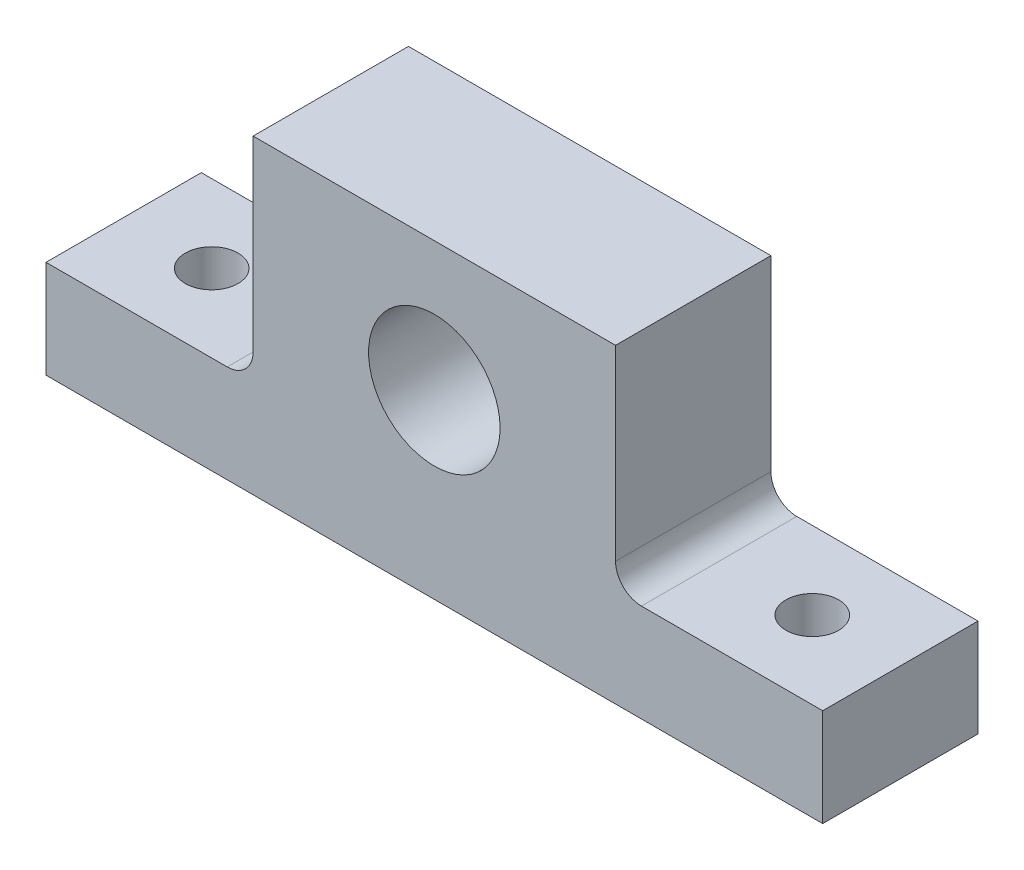
from build123d import *

# Parameters (mm, degrees)
BOSS_EXTRUDE1_DEPTH               = 30
F_1_1_0000_DOWEL_HOLE1_D          = 25.4
TAP_DRILL_FOR_M12X1_75_TAP1_D     = 10.2
TAP_DRILL_FOR_M12X1_75_TAP1_DEPTH = 30
TAP_DRILL_FOR_M12X1_75_TAP1_TIP   = 3.064389157


with BuildPart() as part:
    # Sketch1 → Boss-Extrude1 (new body)
    with BuildSketch(Plane.XY):
        with BuildLine():
            Line((-75, -23.452240915), (75, -23.452240915))
            Line((75, -23.452240915), (75, -4.569806156))
            Line((75, -4.569806156), (40, -4.569806156))
            ThreePointArc((40, -4.569806156), (36.464466094, -3.105340062), (35, 0.430193844))
            Line((35, 0.430193844), (35, 36.547759085))
            Line((35, 36.547759085), (-35, 36.547759085))
            Line((-35, 36.547759085), (-35, 0.430193844))
            ThreePointArc((-35, 0.430193844), (-36.464466094, -3.105340062), (-40, -4.569806156))
            Line((-40, -4.569806156), (-75, -4.569806156))
            Line((-75, -4.569806156), (-75, -23.452240915))
        make_face()
    extrude(amount=BOSS_EXTRUDE1_DEPTH)

    # 1 (1.0000) Dowel Hole1 (through all)
    with Locations(Plane.XY.offset(30)):
        with Locations((0, 11.547759085)):
            Hole(F_1_1_0000_DOWEL_HOLE1_D / 2)

    # Tap Drill for M12x1.75 Tap1
    with Locations(Plane(origin=(0, -4.569806156, 0), x_dir=(1, 0, 0), z_dir=(0, 1, 0))):
        with Locations((58, -15), (-58, -15)):
            Hole(TAP_DRILL_FOR_M12X1_75_TAP1_D / 2, depth=TAP_DRILL_FOR_M12X1_75_TAP1_DEPTH)
            with Locations((0, 0, -(TAP_DRILL_FOR_M12X1_75_TAP1_DEPTH + TAP_DRILL_FOR_M12X1_75_TAP1_TIP / 2))):  # 118° drill point
                Cone(0, TAP_DRILL_FOR_M12X1_75_TAP1_D / 2, TAP_DRILL_FOR_M12X1_75_TAP1_TIP, mode=Mode.SUBTRACT)


solid = part.part
